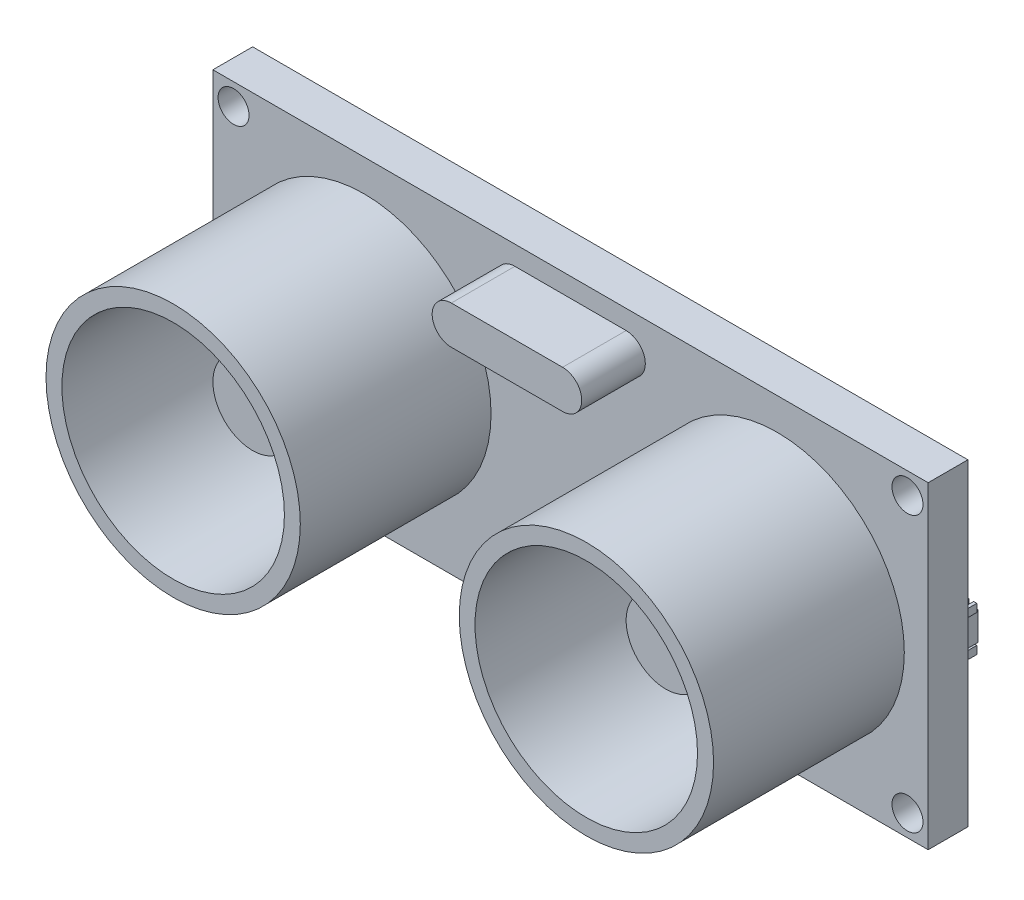
from build123d import *

# Parameters (mm, degrees)
SKETCH1_W                     = 45
SKETCH1_H                     = 20
BOSS_EXTRUDE1_DEPTH           = 2.5
SKETCH2_R                     = 8
BOSS_EXTRUDE2_DEPTH           = 12
SKETCH3_R                     = 7
CUT_EXTRUDE2_DEPTH            = 12
SKETCH5_R                     = 4
BOSS_EXTRUDE3_DEPTH           = 5
SKETCH6_R                     = 2.5
BOSS_EXTRUDE4_DEPTH           = 2
SKETCH7_R                     = 0.975
CUT_EXTRUDE4_DEPTH            = 12
BOSS_EXTRUDE5_DEPTH           = 4
SKETCH9_W                     = 5.114623348
SKETCH9_H                     = 1.793906496
BOSS_EXTRUDE6_DEPTH           = 1
SKETCH10_W                    = 5.787553774
SKETCH10_H                    = 1.929184592
SKETCH10_W_2                  = 2.12210305
SKETCH10_H_2                  = 4.630043018
BOSS_EXTRUDE7_DEPTH           = 1
SKETCH12_R                    = 1
BOSS_EXTRUDE8_DEPTH           = 0.5
BOSS_EXTRUDE8_DRAFT           = 62
BOSS_EXTRUDE8_PROFILE_2_DEPTH = 0.5
BOSS_EXTRUDE8_PROFILE_2_DRAFT = 62
BOSS_EXTRUDE8_PROFILE_3_DEPTH = 0.5
BOSS_EXTRUDE8_PROFILE_3_DRAFT = 62
BOSS_EXTRUDE8_PROFILE_4_DEPTH = 0.5
BOSS_EXTRUDE8_PROFILE_4_DRAFT = 62
SKETCH15_W                    = 0.2
SKETCH15_H                    = 0.5
BOSS_EXTRUDE10_DEPTH          = 0.8
SKETCH16_W                    = 0.2
SKETCH16_H                    = 0.5
BOSS_EXTRUDE11_DEPTH          = 0.8
SKETCH17_W                    = 0.543338261
SKETCH17_H                    = 0.2
SKETCH17_W_2                  = 0.5
BOSS_EXTRUDE12_DEPTH          = 0.8
SKETCH18_W                    = 9
SKETCH18_H                    = 2
BOSS_EXTRUDE14_DEPTH          = 3
SKETCH19_W                    = 0.5
SKETCH19_H                    = 0.5
BOSS_EXTRUDE15_DEPTH          = 1
SKETCH20_W                    = 0.5
SKETCH20_H                    = 0.512361053
BOSS_EXTRUDE16_DEPTH          = 7


with BuildPart() as part:
    # Sketch1 → Boss-Extrude1 (new body)
    with BuildSketch(Plane.XY):
        Rectangle(SKETCH1_W, SKETCH1_H)
    extrude(amount=BOSS_EXTRUDE1_DEPTH)

    # Sketch2 → Boss-Extrude2 (add)
    with BuildSketch(Plane.XY.offset(2.5)):
        with Locations((-13, 0)):
            Circle(SKETCH2_R)
        with Locations((13, 0)):
            Circle(SKETCH2_R)
    extrude(amount=BOSS_EXTRUDE2_DEPTH)

    # Sketch3 → Cut-Extrude2 (cut)
    with BuildSketch(Plane.XY.offset(14.5)):
        with Locations((-13, -0.01)):
            Circle(SKETCH3_R)
        with Locations((12.99, 0)):
            Circle(SKETCH3_R)
    extrude(amount=-CUT_EXTRUDE2_DEPTH, mode=Mode.SUBTRACT)

    # Sketch5 → Boss-Extrude3 (add)
    with BuildSketch(Plane.XY.offset(2.5)):
        with Locations((-13, 0)):
            Circle(SKETCH5_R)
        with Locations((13, 0)):
            Circle(SKETCH5_R)
    extrude(amount=BOSS_EXTRUDE3_DEPTH)

    # Sketch6 → Boss-Extrude4 (add)
    with BuildSketch(Plane.XY.offset(7.5)):
        with Locations((-13, 0)):
            Circle(SKETCH6_R)
        with Locations((13, 0)):
            Circle(SKETCH6_R)
    extrude(amount=BOSS_EXTRUDE4_DEPTH)

    # Sketch7 → Cut-Extrude4 (cut)
    with BuildSketch(Plane.XY.offset(2.5)):
        with Locations((-21.2, 8.65)):
            Circle(SKETCH7_R)
        with Locations((-21.2, -8.65)):
            Circle(SKETCH7_R)
        with Locations((21.2, -8.65)):
            Circle(SKETCH7_R)
        with Locations((21.2, 8.65)):
            Circle(SKETCH7_R)
    extrude(amount=-CUT_EXTRUDE4_DEPTH, mode=Mode.SUBTRACT)

    # Sketch8 → Boss-Extrude5 (add)
    with BuildSketch(Plane.XY.offset(2.5)):
        with BuildLine():
            Line((-3.5, 8.79), (3.5, 8.79))
            ThreePointArc((3.5, 8.79), (4.705, 7.585), (3.5, 6.38))
            Line((3.5, 6.38), (-3.5, 6.38))
            ThreePointArc((-3.5, 6.38), (-4.705, 7.585), (-3.5, 8.79))
        make_face()
    extrude(amount=BOSS_EXTRUDE5_DEPTH)

    # Sketch9 → Boss-Extrude6 (add)
    with BuildSketch(Plane(origin=(0, 0, 0), x_dir=(-1, 0, 0), z_dir=(0, 0, -1))):
        with Locations((-19.57865581, 0.260557507)):
            Rectangle(SKETCH9_W, SKETCH9_H)
    extrude(amount=BOSS_EXTRUDE6_DEPTH)

    # Sketch10 → Boss-Extrude7 (add)
    with BuildSketch(Plane(origin=(0, 0, 0), x_dir=(-1, 0, 0), z_dir=(0, 0, -1))):
        Rectangle(SKETCH10_W, SKETCH10_H)
        with Locations((20.474629453, 0)):
            Rectangle(SKETCH10_W_2, SKETCH10_H_2)
    extrude(amount=BOSS_EXTRUDE7_DEPTH)


with BuildPart() as boss_extrude8_tool:
    # Sketch12 → Boss-Extrude8 (with draft: the straight prism first)
    with BuildSketch(Plane(origin=(0, 0, 0), x_dir=(-1, 0, 0), z_dir=(0, 0, -1))):
        with Locations((-15.489821973, 5.02753168)):
            Circle(SKETCH12_R)
    extrude(amount=BOSS_EXTRUDE8_DEPTH)
    # Boss-Extrude8: the draft: its side faces are tilted about the plane it starts from
    boss_extrude8_sides = [boss_extrude8_tool.faces().sort_by_distance(p)[0] for p in [
        (16.489821973, 5.02753168, -0.25),
    ]]
    draft(boss_extrude8_sides, Plane(origin=(0, 0, 0), x_dir=(-1, 0, 0), z_dir=(0, 0, -1)), BOSS_EXTRUDE8_DRAFT)


with BuildPart() as part_1:
    add(part.part)

    # Boss-Extrude8: add boss_extrude8_tool
    add(boss_extrude8_tool.part)


with BuildPart() as boss_extrude8_profile_2_tool:
    # Sketch12 → Boss-Extrude8 profile 2 (with draft: the straight prism first)
    with BuildSketch(Plane(origin=(0, 0, 0), x_dir=(-1, 0, 0), z_dir=(0, 0, -1))):
        with Locations((-15.489821973, -5.306891018)):
            Circle(SKETCH12_R)
    extrude(amount=BOSS_EXTRUDE8_PROFILE_2_DEPTH)
    # Boss-Extrude8 profile 2: the draft: its side faces are tilted about the plane it starts from
    boss_extrude8_profile_2_sides = [boss_extrude8_profile_2_tool.faces().sort_by_distance(p)[0] for p in [
        (16.489821973, -5.306891018, -0.25),
    ]]
    draft(boss_extrude8_profile_2_sides, Plane(origin=(0, 0, 0), x_dir=(-1, 0, 0), z_dir=(0, 0, -1)), BOSS_EXTRUDE8_PROFILE_2_DRAFT)


with BuildPart() as part_2:
    add(part_1.part)

    # Boss-Extrude8 profile 2: add boss_extrude8_profile_2_tool
    add(boss_extrude8_profile_2_tool.part)


with BuildPart() as boss_extrude8_profile_3_tool:
    # Sketch12 → Boss-Extrude8 profile 3 (with draft: the straight prism first)
    with BuildSketch(Plane(origin=(0, 0, 0), x_dir=(-1, 0, 0), z_dir=(0, 0, -1))):
        with Locations((13.77726311, -5.306891018)):
            Circle(SKETCH12_R)
    extrude(amount=BOSS_EXTRUDE8_PROFILE_3_DEPTH)
    # Boss-Extrude8 profile 3: the draft: its side faces are tilted about the plane it starts from
    boss_extrude8_profile_3_sides = [boss_extrude8_profile_3_tool.faces().sort_by_distance(p)[0] for p in [
        (-12.77726311, -5.306891018, -0.25),
    ]]
    draft(boss_extrude8_profile_3_sides, Plane(origin=(0, 0, 0), x_dir=(-1, 0, 0), z_dir=(0, 0, -1)), BOSS_EXTRUDE8_PROFILE_3_DRAFT)


with BuildPart() as part_3:
    add(part_2.part)

    # Boss-Extrude8 profile 3: add boss_extrude8_profile_3_tool
    add(boss_extrude8_profile_3_tool.part)


with BuildPart() as boss_extrude8_profile_4_tool:
    # Sketch12 → Boss-Extrude8 profile 4 (with draft: the straight prism first)
    with BuildSketch(Plane(origin=(0, 0, 0), x_dir=(-1, 0, 0), z_dir=(0, 0, -1))):
        with Locations((13.77726311, 5.02753168)):
            Circle(SKETCH12_R)
    extrude(amount=BOSS_EXTRUDE8_PROFILE_4_DEPTH)
    # Boss-Extrude8 profile 4: the draft: its side faces are tilted about the plane it starts from
    boss_extrude8_profile_4_sides = [boss_extrude8_profile_4_tool.faces().sort_by_distance(p)[0] for p in [
        (-12.77726311, 5.02753168, -0.25),
    ]]
    draft(boss_extrude8_profile_4_sides, Plane(origin=(0, 0, 0), x_dir=(-1, 0, 0), z_dir=(0, 0, -1)), BOSS_EXTRUDE8_PROFILE_4_DRAFT)


with BuildPart() as part_4:
    add(part_3.part)

    # Boss-Extrude8 profile 4: add boss_extrude8_profile_4_tool
    add(boss_extrude8_profile_4_tool.part)

    # Boss-Extrude9 cone 1 section (through the dimple's axis) → Boss-Extrude9 (revolve)
    with BuildSketch(Plane(origin=(3.327843419, 7.137982987, 0), x_dir=(0, -1, 0), z_dir=(1, 0, 0))):
        Polygon((0, 0), (0.5, 0), (0, 0.5), align=None)
    revolve(axis=Axis((3.327843419, 7.137982987, 0), (0, 0, -1)))

    # Boss-Extrude9 cone 2 section (through the dimple's axis) → Boss-Extrude9 cone 2 (revolve)
    with BuildSketch(Plane(origin=(-3.954828412, 7.137982987, 0), x_dir=(0, -1, 0), z_dir=(1, 0, 0))):
        Polygon((0, 0), (0.5, 0), (0, 0.5), align=None)
    revolve(axis=Axis((-3.954828412, 7.137982987, 0), (0, 0, -1)))

    # Sketch15 → Boss-Extrude10 (add)
    with BuildSketch(Plane.XY.offset(-0.8)):
        with Locations((22.157898059, 1.407510755)):
            Rectangle(SKETCH15_W, SKETCH15_H)
        with Locations((21.657898059, 1.407510755)):
            Rectangle(SKETCH15_W, SKETCH15_H)
        with Locations((22.157898059, -0.886395741)):
            Rectangle(SKETCH15_W, SKETCH15_H)
        with Locations((21.657898059, -0.886395741)):
            Rectangle(SKETCH15_W, SKETCH15_H)
        with Locations((21.157898059, 1.407510755)):
            Rectangle(SKETCH15_W, SKETCH15_H)
        with Locations((21.157898059, -0.886395741)):
            Rectangle(SKETCH15_W, SKETCH15_H)
        with Locations((20.657898059, 1.407510755)):
            Rectangle(SKETCH15_W, SKETCH15_H)
        with Locations((20.657898059, -0.886395741)):
            Rectangle(SKETCH15_W, SKETCH15_H)
        with Locations((20.157898059, 1.407510755)):
            Rectangle(SKETCH15_W, SKETCH15_H)
        with Locations((20.157898059, -0.886395741)):
            Rectangle(SKETCH15_W, SKETCH15_H)
        with Locations((19.657898059, 1.407510755)):
            Rectangle(SKETCH15_W, SKETCH15_H)
        with Locations((19.657898059, -0.886395741)):
            Rectangle(SKETCH15_W, SKETCH15_H)
        with Locations((19.157898059, 1.407510755)):
            Rectangle(SKETCH15_W, SKETCH15_H)
        with Locations((19.157898059, -0.886395741)):
            Rectangle(SKETCH15_W, SKETCH15_H)
        with Locations((18.657898059, 1.407510755)):
            Rectangle(SKETCH15_W, SKETCH15_H)
        with Locations((18.657898059, -0.886395741)):
            Rectangle(SKETCH15_W, SKETCH15_H)
        with Locations((18.157898059, 1.407510755)):
            Rectangle(SKETCH15_W, SKETCH15_H)
        with Locations((18.157898059, -0.886395741)):
            Rectangle(SKETCH15_W, SKETCH15_H)
        with Locations((17.657898059, 1.407510755)):
            Rectangle(SKETCH15_W, SKETCH15_H)
        with Locations((17.657898059, -0.886395741)):
            Rectangle(SKETCH15_W, SKETCH15_H)
    extrude(amount=BOSS_EXTRUDE10_DEPTH)

    # Sketch16 → Boss-Extrude11 (add)
    with BuildSketch(Plane.XY.offset(-0.8)):
        with Locations((2.666399474, 1.214592296)):
            Rectangle(SKETCH16_W, SKETCH16_H)
        with Locations((2.166399474, 1.214592296)):
            Rectangle(SKETCH16_W, SKETCH16_H)
        with Locations((2.666399474, -1.214592296)):
            Rectangle(SKETCH16_W, SKETCH16_H)
        with Locations((2.166399474, -1.214592296)):
            Rectangle(SKETCH16_W, SKETCH16_H)
        with Locations((1.666399474, 1.214592296)):
            Rectangle(SKETCH16_W, SKETCH16_H)
        with Locations((1.666399474, -1.214592296)):
            Rectangle(SKETCH16_W, SKETCH16_H)
        with Locations((1.166399474, 1.214592296)):
            Rectangle(SKETCH16_W, SKETCH16_H)
        with Locations((1.166399474, -1.214592296)):
            Rectangle(SKETCH16_W, SKETCH16_H)
        with Locations((0.666399474, 1.214592296)):
            Rectangle(SKETCH16_W, SKETCH16_H)
        with Locations((0.666399474, -1.214592296)):
            Rectangle(SKETCH16_W, SKETCH16_H)
        with Locations((0.166399474, 1.214592296)):
            Rectangle(SKETCH16_W, SKETCH16_H)
        with Locations((0.166399474, -1.214592296)):
            Rectangle(SKETCH16_W, SKETCH16_H)
        with Locations((-0.333600526, 1.214592296)):
            Rectangle(SKETCH16_W, SKETCH16_H)
        with Locations((-0.333600526, -1.214592296)):
            Rectangle(SKETCH16_W, SKETCH16_H)
        with Locations((-0.833600526, 1.214592296)):
            Rectangle(SKETCH16_W, SKETCH16_H)
        with Locations((-0.833600526, -1.214592296)):
            Rectangle(SKETCH16_W, SKETCH16_H)
        with Locations((-1.333600526, 1.214592296)):
            Rectangle(SKETCH16_W, SKETCH16_H)
        with Locations((-1.333600526, -1.214592296)):
            Rectangle(SKETCH16_W, SKETCH16_H)
        with Locations((-1.833600526, 1.214592296)):
            Rectangle(SKETCH16_W, SKETCH16_H)
        with Locations((-1.833600526, -1.214592296)):
            Rectangle(SKETCH16_W, SKETCH16_H)
        with Locations((-2.333600526, 1.214592296)):
            Rectangle(SKETCH16_W, SKETCH16_H)
        with Locations((-2.333600526, -1.214592296)):
            Rectangle(SKETCH16_W, SKETCH16_H)
    extrude(amount=BOSS_EXTRUDE11_DEPTH)

    # Sketch17 → Boss-Extrude12 (add)
    with BuildSketch(Plane.XY.offset(-0.8)):
        with Locations((-21.807350109, 2.011896392)):
            Rectangle(SKETCH17_W, SKETCH17_H)
        with Locations((-19.163577928, 2.011896392)):
            Rectangle(SKETCH17_W_2, SKETCH17_H)
        with Locations((-19.163577928, 1.511896392)):
            Rectangle(SKETCH17_W_2, SKETCH17_H)
        with Locations((-21.807350109, 1.511896392)):
            Rectangle(SKETCH17_W, SKETCH17_H)
        with Locations((-19.163577928, 1.011896392)):
            Rectangle(SKETCH17_W_2, SKETCH17_H)
        with Locations((-21.807350109, 1.011896392)):
            Rectangle(SKETCH17_W, SKETCH17_H)
        with Locations((-19.163577928, 0.511896392)):
            Rectangle(SKETCH17_W_2, SKETCH17_H)
        with Locations((-21.807350109, 0.511896392)):
            Rectangle(SKETCH17_W, SKETCH17_H)
        with Locations((-19.163577928, 0.011896392)):
            Rectangle(SKETCH17_W_2, SKETCH17_H)
        with Locations((-21.807350109, 0.011896392)):
            Rectangle(SKETCH17_W, SKETCH17_H)
        with Locations((-19.163577928, -0.488103608)):
            Rectangle(SKETCH17_W_2, SKETCH17_H)
        with Locations((-21.807350109, -0.488103608)):
            Rectangle(SKETCH17_W, SKETCH17_H)
        with Locations((-19.163577928, -0.988103608)):
            Rectangle(SKETCH17_W_2, SKETCH17_H)
        with Locations((-21.807350109, -0.988103608)):
            Rectangle(SKETCH17_W, SKETCH17_H)
        with Locations((-19.163577928, -1.488103608)):
            Rectangle(SKETCH17_W_2, SKETCH17_H)
        with Locations((-21.807350109, -1.488103608)):
            Rectangle(SKETCH17_W, SKETCH17_H)
        with Locations((-19.163577928, -1.988103608)):
            Rectangle(SKETCH17_W_2, SKETCH17_H)
        with Locations((-21.807350109, -1.988103608)):
            Rectangle(SKETCH17_W, SKETCH17_H)
    extrude(amount=BOSS_EXTRUDE12_DEPTH)

    # Sketch18 → Boss-Extrude14 (add)
    with BuildSketch(Plane(origin=(0, 0, 0), x_dir=(-1, 0, 0), z_dir=(0, 0, -1))):
        with Locations((0, -8.199034512)):
            Rectangle(SKETCH18_W, SKETCH18_H)
    extrude(amount=BOSS_EXTRUDE14_DEPTH)

    # Sketch19 → Boss-Extrude15 (add)
    with BuildSketch(Plane(origin=(0, 0, -3), x_dir=(-1, 0, 0), z_dir=(0, 0, -1))):
        with Locations((-3.607952931, -8.205999129)):
            Rectangle(SKETCH19_W, SKETCH19_H)
        with Locations((-1.107952931, -8.205999129)):
            Rectangle(SKETCH19_W, SKETCH19_H)
        with Locations((1.392047069, -8.205999129)):
            Rectangle(SKETCH19_W, SKETCH19_H)
        with Locations((3.892047069, -8.205999129)):
            Rectangle(SKETCH19_W, SKETCH19_H)
    extrude(amount=BOSS_EXTRUDE15_DEPTH)

    # Sketch20 → Boss-Extrude16 (add)
    with BuildSketch(Plane.XZ.offset(8.455999129)):
        with Locations((3.607952931, -3.743819474)):
            Rectangle(SKETCH20_W, SKETCH20_H)
        with Locations((1.107952931, -3.743819474)):
            Rectangle(SKETCH20_W, SKETCH20_H)
        with Locations((-1.392047069, -3.743819474)):
            Rectangle(SKETCH20_W, SKETCH20_H)
        with Locations((-3.892047069, -3.743819474)):
            Rectangle(SKETCH20_W, SKETCH20_H)
    extrude(amount=BOSS_EXTRUDE16_DEPTH)


solid = part_4.part
